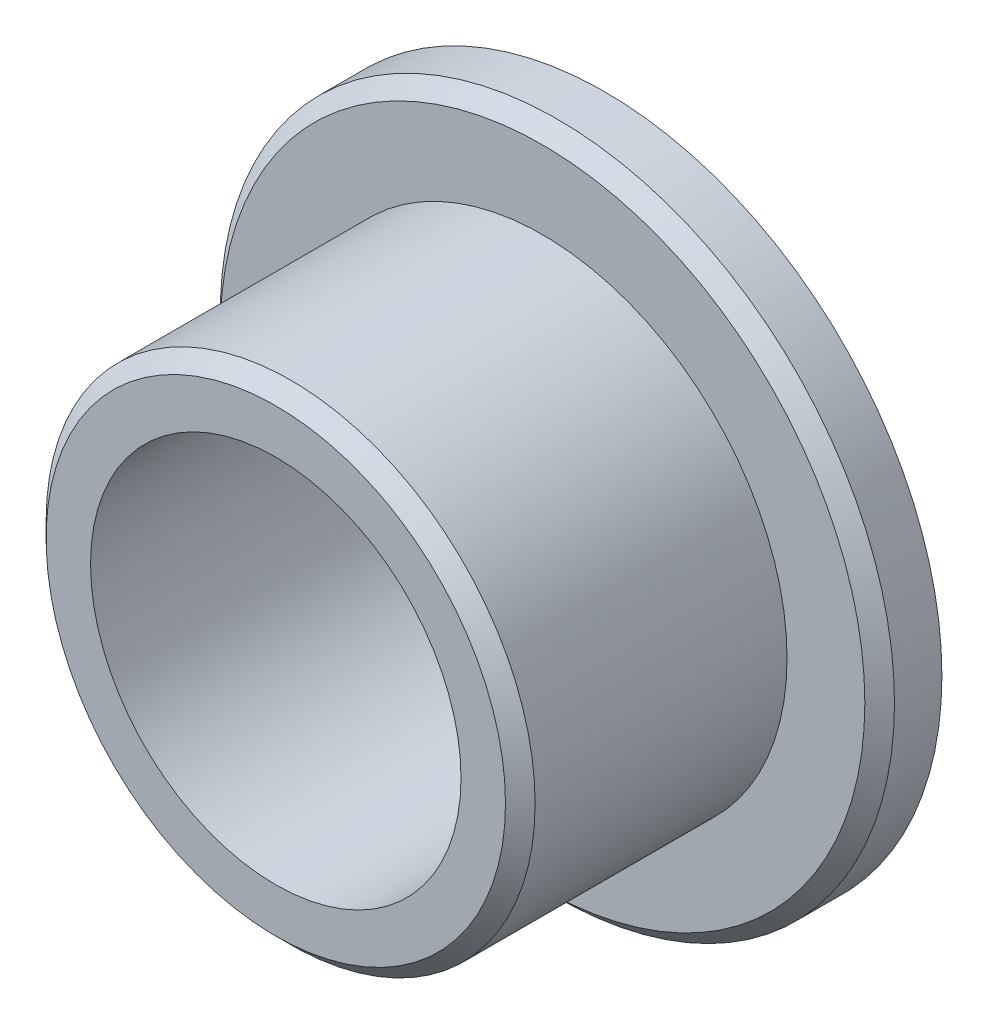
from build123d import *

# Parameters (mm, degrees)
SKETCH_1_R          = 22.75
EXTRUDE_1_DEPTH     = 4.2
SKETCH_2_R          = 16.5
EXTRUDE_2_DEPTH     = 18
SKETCH_3_R          = 12.5
CUT_EXTRUDE_1_DEPTH = 23.2
CHAMFER_1_SIZE      = 1


with BuildPart() as part:
    # 草图1 → 凸台-拉伸1 (new body)
    with BuildSketch(Plane.XY):
        Circle(SKETCH_1_R)
    extrude(amount=EXTRUDE_1_DEPTH)

    # 草图2 → 凸台-拉伸2 (add)
    with BuildSketch(Plane.XY.offset(4.2)):
        Circle(SKETCH_2_R)
    extrude(amount=EXTRUDE_2_DEPTH)

    # 草图3 → 切除-拉伸1 (cut, through all)
    with BuildSketch(Plane.XY.offset(22.2)):
        Circle(SKETCH_3_R)
    extrude(amount=-CUT_EXTRUDE_1_DEPTH, mode=Mode.SUBTRACT)

    # 倒角1
    chamfer_1_edges = [part.edges().sort_by_distance(p)[0] for p in [
        (-22.75, 0, 4.2),
        (-16.5, 0, 22.2),
    ]]
    chamfer(chamfer_1_edges, length=CHAMFER_1_SIZE)


solid = part.part
